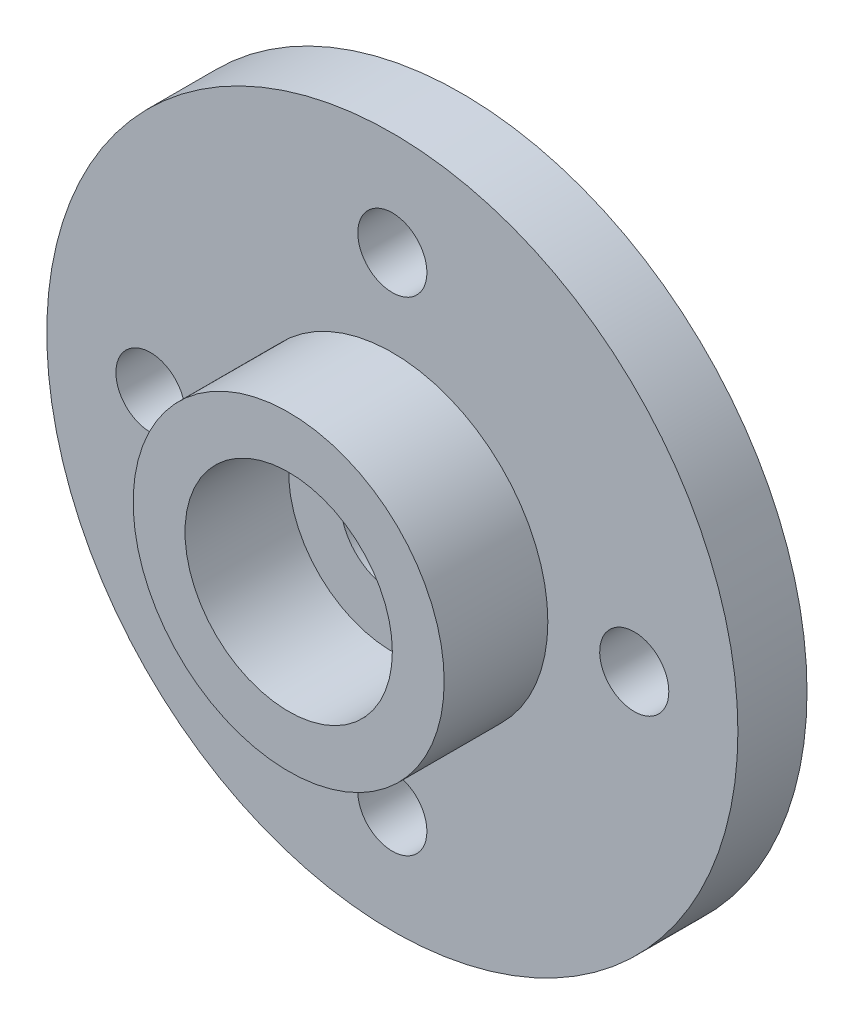
from build123d import *

# Parameters (mm, degrees)
SKETCH1_R           = 10
SKETCH1_R_2         = 1.5
BOSS_EXTRUDE1_DEPTH = 2
SKETCH2_R           = 4.5
SKETCH2_R_2         = 3
BOSS_EXTRUDE2_DEPTH = 3
SKETCH3_R           = 1
CUT_EXTRUDE1_DEPTH  = 2
CIRPATTERN1_COUNT   = 4


with BuildPart() as part:
    # Sketch1 → Boss-Extrude1 (new body)
    with BuildSketch(Plane.XY):
        Circle(SKETCH1_R)
        Circle(SKETCH1_R_2, mode=Mode.SUBTRACT)
    extrude(amount=BOSS_EXTRUDE1_DEPTH)

    # Sketch2 → Boss-Extrude2 (add)
    with BuildSketch(Plane.XY.offset(2)):
        Circle(SKETCH2_R)
        Circle(SKETCH2_R_2, mode=Mode.SUBTRACT)
    extrude(amount=BOSS_EXTRUDE2_DEPTH)

    # Sketch3 → Cut-Extrude1 (cut)
    with BuildSketch(Plane(origin=(0, 0, 0), x_dir=(-1, 0, 0), z_dir=(0, 0, -1))):
        with Locations((0, 7)):
            Circle(SKETCH3_R)
    cut_extrude1 = extrude(amount=-CUT_EXTRUDE1_DEPTH, mode=Mode.SUBTRACT)

    # CirPattern1: Cut-Extrude1 ×4 about axis
    cirpattern1_axis = Axis((0, 0, 0), (0, 0, 1))
    for i in range(1, CIRPATTERN1_COUNT):
        add(cut_extrude1.rotate(cirpattern1_axis, i * 360 / CIRPATTERN1_COUNT), mode=Mode.SUBTRACT)


solid = part.part
